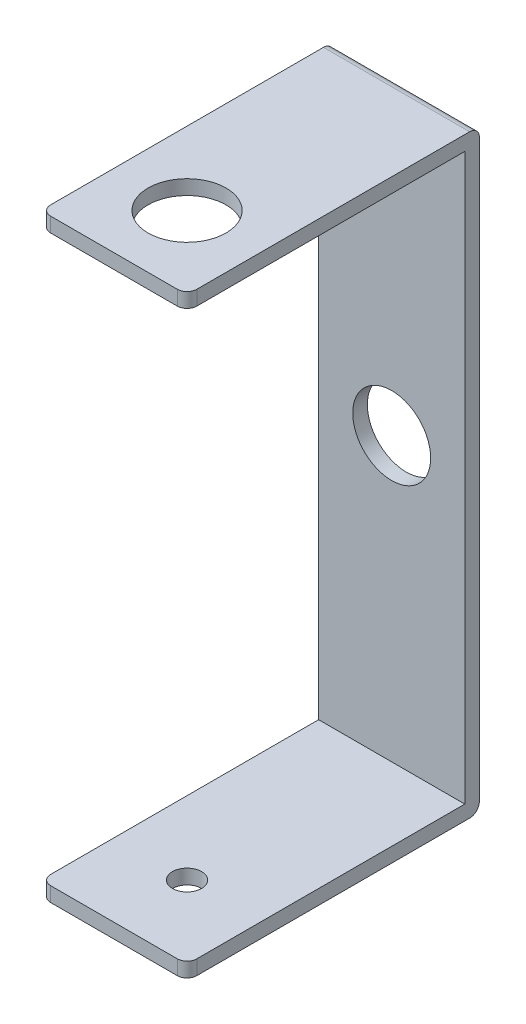
from build123d import *

# Parameters (mm, degrees)
SKETCH1_R           = 4
BOSS_EXTRUDE1_DEPTH = 1.5
SKETCH2_W           = 15
SKETCH2_H           = 1.5
BOSS_EXTRUDE2_DEPTH = 28.5
SKETCH3_R           = 1.5
CUT_EXTRUDE1_DEPTH  = 62
FILLET1_R           = 1
CUT_EXTRUDE2_REACH  = 63
SKETCH5_R           = 4


with BuildPart() as part:
    # Sketch1 → Boss-Extrude1 (new body)
    with BuildSketch(Plane.XY):
        Polygon((-7.5, -23.042592662), (-7.5, -30.5), (7.5, -30.5), (7.5, -23.042592662), (7.5, 26.84732779), (7.5, 30.5), (-7.5, 30.5), (-7.5, 26.84732779), align=None)
        Circle(SKETCH1_R, mode=Mode.SUBTRACT)
    extrude(amount=BOSS_EXTRUDE1_DEPTH)

    # Sketch2 → Boss-Extrude2 (add)
    with BuildSketch(Plane.XY.offset(1.5)):
        with Locations((0, 29.75)):
            Rectangle(SKETCH2_W, SKETCH2_H)
        with Locations((0, -29.75)):
            Rectangle(SKETCH2_W, SKETCH2_H)
    extrude(amount=BOSS_EXTRUDE2_DEPTH)

    # Sketch3 → Cut-Extrude1 (cut, through all)
    with BuildSketch(Plane(origin=(0, 30.5, 0), x_dir=(1, 0, 0), z_dir=(0, 1, 0))):
        with Locations((0, -22.5)):
            Circle(SKETCH3_R)
    extrude(amount=-CUT_EXTRUDE1_DEPTH, mode=Mode.SUBTRACT)

    # Fillet1
    fillet1_edges = [part.edges().sort_by_distance(p)[0] for p in [
        (0, -30.5, 0),
        (-7.5, -29.75, 30),
        (7.5, -29.75, 30),
        (7.5, 29.75, 30),
        (-7.5, 29.75, 30),
        (0, 30.5, 0),
    ]]
    fillet(fillet1_edges, radius=FILLET1_R)

    # Sketch5 → Cut-Extrude2 (cut, up to next)
    with BuildSketch(Plane(origin=(0, 30.5, 0), x_dir=(1, 0, 0), z_dir=(0, 1, 0)), mode=Mode.PRIVATE) as cut_extrude2_sk1:
        with Locations((0, -22.5)):
            Circle(SKETCH5_R)
    cut_extrude2_tool1 = extrude(cut_extrude2_sk1.sketch, amount=-CUT_EXTRUDE2_REACH, mode=Mode.PRIVATE) & part.part
    add(cut_extrude2_tool1.solids().sort_by_distance((0, 30.5, 22.5))[0], mode=Mode.SUBTRACT)


solid = part.part
